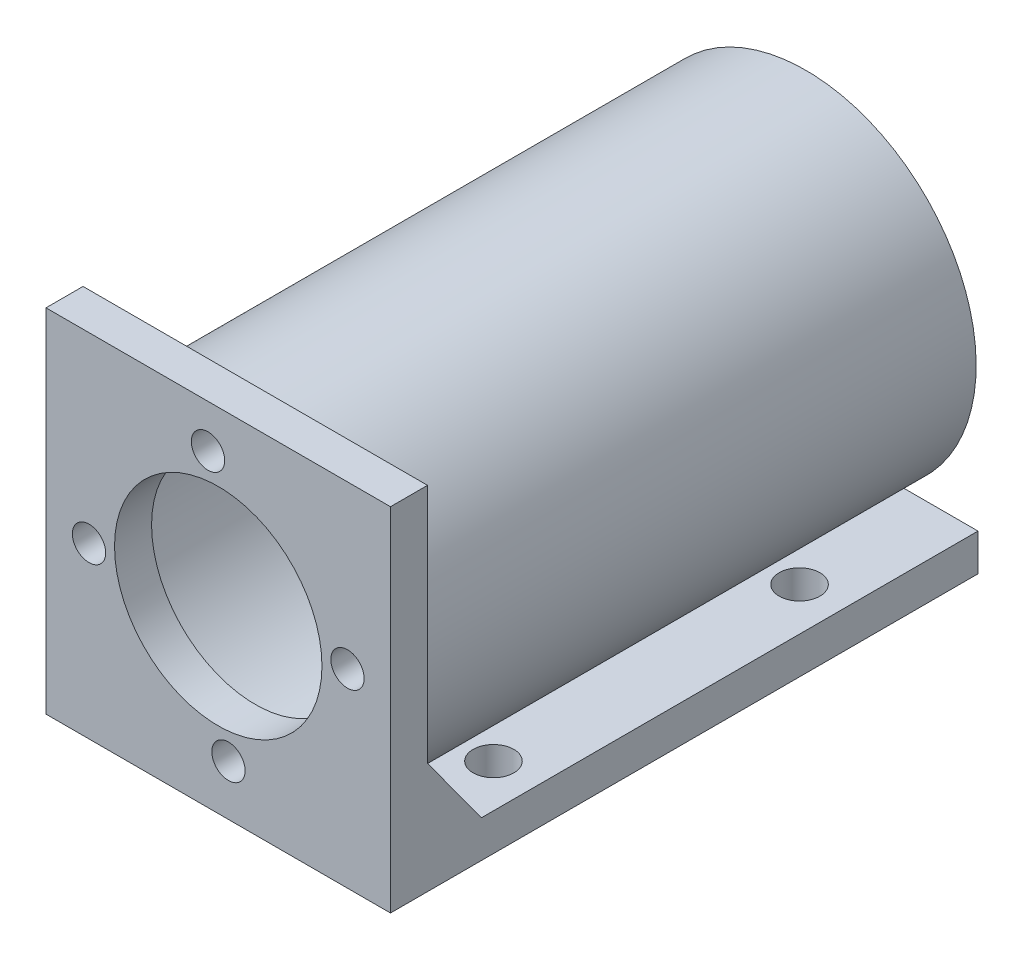
from build123d import *

# Parameters (mm, degrees)
SKETCH1_W           = 46.5
SKETCH1_H           = 46.5
SKETCH1_R           = 14
SKETCH1_R_2         = 2.25
BOSS_EXTRUDE1_DEPTH = 5
SKETCH2_W           = 46.5
SKETCH2_H           = 5
BOSS_EXTRUDE2_DEPTH = 149
SKETCH4_W           = 46.5
SKETCH4_H           = 5
BOSS_EXTRUDE3_DEPTH = 1
SKETCH5_R           = 2.75
CUT_EXTRUDE1_DEPTH  = 10
SKETCH9_R           = 23
CUT_EXTRUDE2_DEPTH  = 149
SKETCH10_R          = 23
SKETCH10_R_2        = 21
BOSS_EXTRUDE4_DEPTH = 149
CHAMFER1_SIZE       = 10
CHAMFER1_SIZE2      = 7.26542528
CHAMFER2_SIZE       = 10
CHAMFER2_SIZE2      = 7.26542528
SKETCH11_W          = 46.5
SKETCH11_H          = 74.694653746
CUT_EXTRUDE3_DEPTH  = 149


with BuildPart() as part:
    # Sketch1 → Boss-Extrude1 (new body)
    with BuildSketch(Plane.XY):
        Rectangle(SKETCH1_W, SKETCH1_H)
        Circle(SKETCH1_R, mode=Mode.SUBTRACT)
        with Locations((-1.381951843, 17.445349211)):
            Circle(SKETCH1_R_2, mode=Mode.SUBTRACT)
        with Locations((17.445349211, 1.381951843)):
            Circle(SKETCH1_R_2, mode=Mode.SUBTRACT)
        with Locations((1.381951843, -17.445349211)):
            Circle(SKETCH1_R_2, mode=Mode.SUBTRACT)
        with Locations((-17.445349211, -1.381951843)):
            Circle(SKETCH1_R_2, mode=Mode.SUBTRACT)
    extrude(amount=BOSS_EXTRUDE1_DEPTH)

    # Sketch2 → Boss-Extrude2 (add)
    with BuildSketch(Plane(origin=(0, 0, 0), x_dir=(-1, 0, 0), z_dir=(0, 0, -1))):
        with Locations((0, -21.75)):
            Rectangle(SKETCH2_W, SKETCH2_H)
    extrude(amount=BOSS_EXTRUDE2_DEPTH)

    # Sketch4 → Boss-Extrude3 (add)
    with BuildSketch(Plane.XZ.offset(23.25)):
        with Locations((0, 2.5)):
            Rectangle(SKETCH4_W, SKETCH4_H)
    extrude(amount=BOSS_EXTRUDE3_DEPTH)

    # Sketch5 → Cut-Extrude1 (cut)
    with BuildSketch(Plane(origin=(0, -19.25, 0), x_dir=(1, 0, 0), z_dir=(0, 1, 0))):
        with Locations((17.443135508, 14.708820521)):
            Circle(SKETCH5_R)
        with Locations((17.443135508, 87.833686256)):
            Circle(SKETCH5_R)
        with Locations((17.443135508, 56.021234434)):
            Circle(SKETCH5_R)
        with Locations((17.443135508, 129.140706858)):
            Circle(SKETCH5_R)
    cut_extrude1 = extrude(amount=-CUT_EXTRUDE1_DEPTH, mode=Mode.SUBTRACT)

    # Mirror1: Cut-Extrude1 across plane
    add(cut_extrude1.mirror(Plane(origin=(0, 0, 0), x_dir=(0, 0, 1), z_dir=(1, 0, 0))), mode=Mode.SUBTRACT)

    # Sketch9 → Cut-Extrude2 (cut)
    with BuildSketch(Plane(origin=(0, 0, -149), x_dir=(-1, 0, 0), z_dir=(0, 0, -1))):
        Circle(SKETCH9_R)
    extrude(amount=-CUT_EXTRUDE2_DEPTH, mode=Mode.SUBTRACT)

    # Sketch10 → Boss-Extrude4 (add)
    with BuildSketch(Plane(origin=(0, 0, -149), x_dir=(-1, 0, 0), z_dir=(0, 0, -1))):
        Circle(SKETCH10_R)
        Circle(SKETCH10_R_2, mode=Mode.SUBTRACT)
    extrude(amount=-BOSS_EXTRUDE4_DEPTH)

    # Chamfer1
    chamfer1_edges = [part.edges().sort_by_distance(p)[0] for p in [
        (17.918597938, -19.25, 0),
    ]]
    chamfer1_side = [part.faces().sort_by_distance(p)[0] for p in [
        (0, 23.062996032, 0),
    ]]
    chamfer(chamfer1_edges, length=CHAMFER1_SIZE, length2=CHAMFER1_SIZE2, reference=chamfer1_side[0])

    # Chamfer2
    chamfer2_edges = [part.edges().sort_by_distance(p)[0] for p in [
        (-17.918597938, -19.25, 0),
    ]]
    chamfer2_side = [part.faces().sort_by_distance(p)[0] for p in [
        (-6.732220056, 22.650656451, 0),
    ]]
    chamfer(chamfer2_edges, length=CHAMFER2_SIZE, length2=CHAMFER2_SIZE2, reference=chamfer2_side[0])

    # Sketch11 → Cut-Extrude3 (cut)
    with BuildSketch(Plane.XZ.offset(24.25)):
        with Locations((0, -111.652673127)):
            Rectangle(SKETCH11_W, SKETCH11_H)
    extrude(amount=-CUT_EXTRUDE3_DEPTH, mode=Mode.SUBTRACT)


solid = part.part
